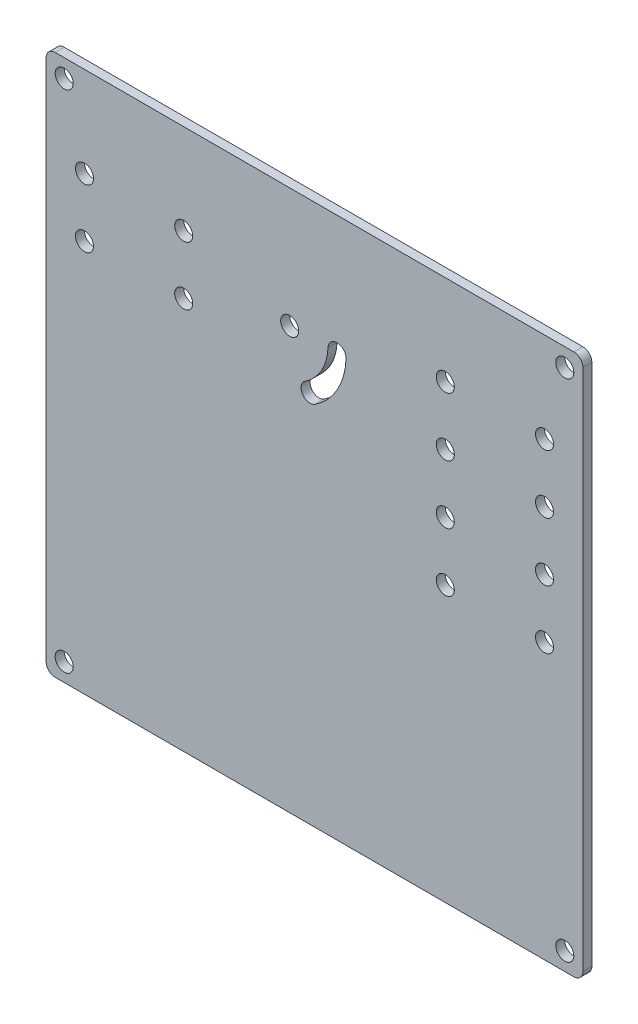
from build123d import *

# Parameters (mm, degrees)
SKETCH_2_W          = 119
SKETCH_2_H          = 120
EXTRUDE_1_DEPTH     = 2
SKETCH_6_R          = 2
CUT_EXTRUDE_3_DEPTH = 2
CUT_EXTRUDE_5_DEPTH = 2
FILLET_1_R          = 2
SKETCH_9_R          = 2
CUT_EXTRUDE_6_DEPTH = 2


with BuildPart() as part:
    # 草图2 → 凸台-拉伸1 (new body)
    with BuildSketch(Plane.XY):
        with Locations((59.5, 60)):
            Rectangle(SKETCH_2_W, SKETCH_2_H)
    extrude(amount=EXTRUDE_1_DEPTH)

    # 草图6 → 切除-拉伸3 (cut)
    with BuildSketch(Plane.XY):
        with Locations((8.5, 100)):
            Circle(SKETCH_6_R)
        with Locations((30.5, 100)):
            Circle(SKETCH_6_R)
        with Locations((8.5, 87)):
            Circle(SKETCH_6_R)
        with Locations((30.5, 87)):
            Circle(SKETCH_6_R)
        with Locations((54, 93.5)):
            Circle(SKETCH_6_R)
        with Locations((88.5, 100)):
            Circle(SKETCH_6_R)
        with Locations((88.5, 87)):
            Circle(SKETCH_6_R)
        with Locations((110.5, 100)):
            Circle(SKETCH_6_R)
        with Locations((110.5, 87)):
            Circle(SKETCH_6_R)
        with Locations((88.5, 74)):
            Circle(SKETCH_6_R)
        with Locations((88.5, 61)):
            Circle(SKETCH_6_R)
        with Locations((110.5, 74)):
            Circle(SKETCH_6_R)
        with Locations((110.5, 61)):
            Circle(SKETCH_6_R)
    extrude(amount=CUT_EXTRUDE_3_DEPTH, mode=Mode.SUBTRACT)

    # 草图7 → 切除-拉伸5 (cut)
    with BuildSketch(Plane.XY):
        with BuildLine():
            ThreePointArc((59.618141264, 81.233145737), (64.538696872, 86.493844671), (66.498605851, 93.425336399))
            ThreePointArc((66.498605851, 93.425336399), (64.574663601, 95.498605851), (62.501394149, 93.574663601))
            ThreePointArc((62.501394149, 93.574663601), (61.055127678, 88.459740312), (57.424125079, 84.577737339))
            ThreePointArc((57.424125079, 84.577737339), (56.848837371, 81.808433446), (59.618141264, 81.233145737))
        make_face()
    extrude(amount=CUT_EXTRUDE_5_DEPTH, mode=Mode.SUBTRACT)

    # 圆角1
    fillet_1_edges = [part.edges().sort_by_distance(p)[0] for p in [
        (0, 0, 1),
        (119, 0, 1),
        (119, 120, 1),
        (0, 120, 1),
    ]]
    fillet(fillet_1_edges, radius=FILLET_1_R)

    # 草图9 → 切除-拉伸6 (cut)
    with BuildSketch(Plane.XY.offset(2)):
        with Locations((4, 116)):
            Circle(SKETCH_9_R)
        with Locations((115, 116)):
            Circle(SKETCH_9_R)
        with Locations((4, 4)):
            Circle(SKETCH_9_R)
        with Locations((115, 4)):
            Circle(SKETCH_9_R)
    extrude(amount=-CUT_EXTRUDE_6_DEPTH, mode=Mode.SUBTRACT)


solid = part.part
